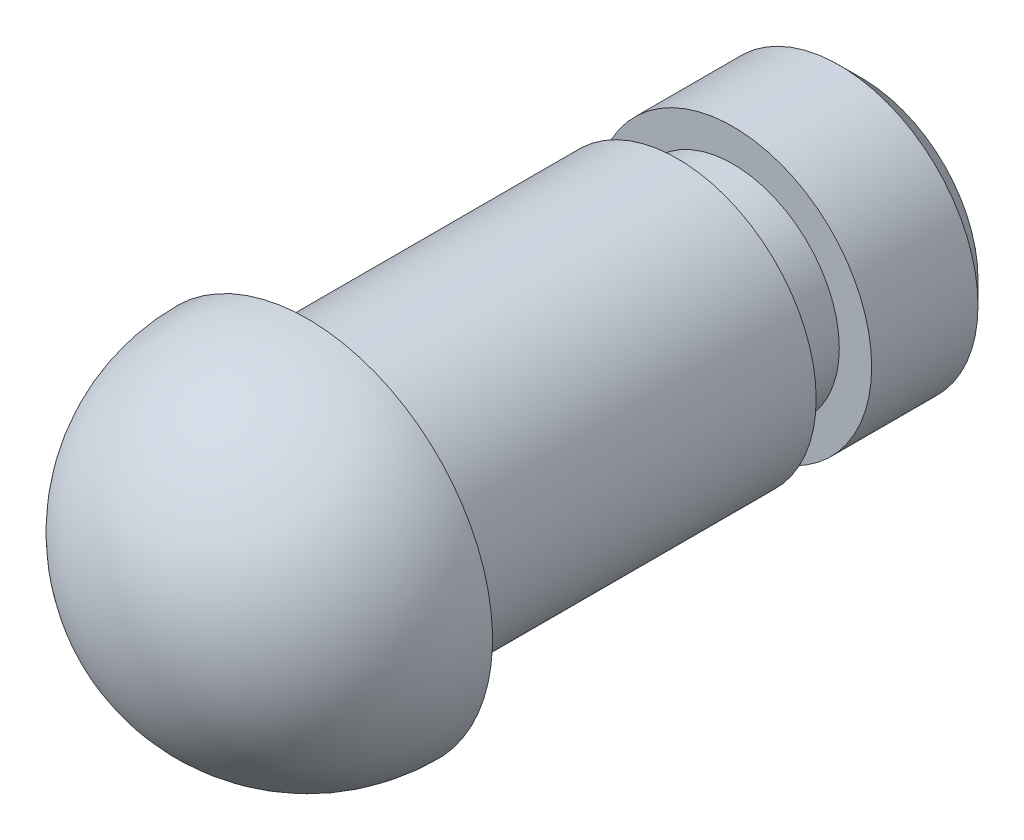
from build123d import *

# Parameters (mm, degrees)
SKETCH1_R           = 1.5
BOSS_EXTRUDE1_DEPTH = 1.4
SKETCH2_R           = 1.15
BOSS_EXTRUDE2_DEPTH = 0.6
SKETCH3_R           = 1.5
BOSS_EXTRUDE3_DEPTH = 4
REVOLVE1_ANGLE      = 180
CHAMFER1_SIZE       = 0.25


with BuildPart() as part:
    # Sketch1 → Boss-Extrude1 (new body)
    with BuildSketch(Plane.XY):
        Circle(SKETCH1_R)
    extrude(amount=BOSS_EXTRUDE1_DEPTH)

    # Sketch2 → Boss-Extrude2 (add)
    with BuildSketch(Plane.XY.offset(1.4)):
        Circle(SKETCH2_R)
    extrude(amount=BOSS_EXTRUDE2_DEPTH)

    # Sketch3 → Boss-Extrude3 (add)
    with BuildSketch(Plane.XY.offset(2)):
        Circle(SKETCH3_R)
    extrude(amount=BOSS_EXTRUDE3_DEPTH)

    # Sketch4 → Revolve1 (revolve)
    with BuildSketch(Plane.XY.offset(6)):
        with BuildLine():
            Line((0, 2), (0, -2))
            ThreePointArc((0, -2), (2, 0), (0, 2))
        make_face()
    revolve(axis=Axis((0, 2, 6), (0, -1, 0)), revolution_arc=REVOLVE1_ANGLE)

    # Chamfer1
    chamfer1_edges = [part.edges().sort_by_distance(p)[0] for p in [
        (-1.5, 0, 0),
    ]]
    chamfer(chamfer1_edges, length=CHAMFER1_SIZE)


solid = part.part
